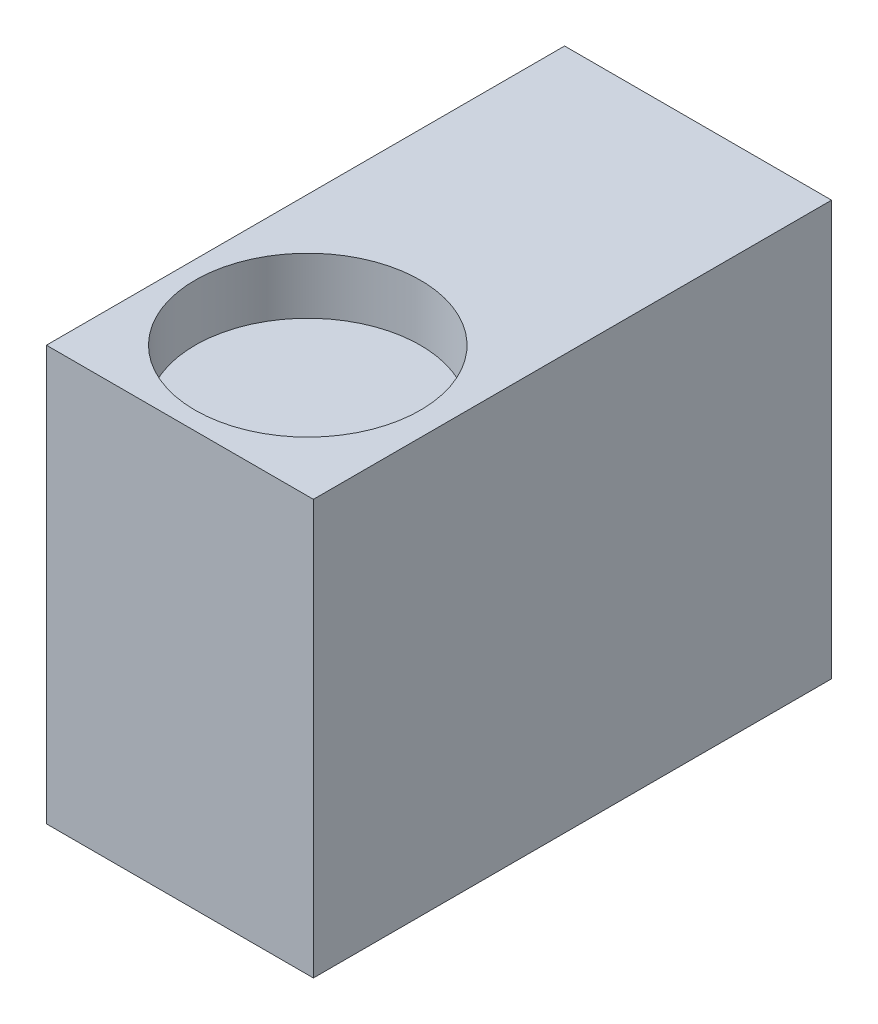
from build123d import *

# Parameters (mm, degrees)
SKETCH1_W           = 23.7
SKETCH1_H           = 36.8
BOSS_EXTRUDE2_DEPTH = 46
SKETCH2_R           = 10
CUT_EXTRUDE1_DEPTH  = 5


with BuildPart() as part:
    # Sketch1 → Boss-Extrude2 (new body)
    with BuildSketch(Plane.XY):
        with Locations((-2.757896825, -4.218611111)):
            Rectangle(SKETCH1_W, SKETCH1_H)
    extrude(amount=BOSS_EXTRUDE2_DEPTH)

    # Sketch2 → Cut-Extrude1 (cut)
    with BuildSketch(Plane(origin=(0, 14.181388889, 0), x_dir=(1, 0, 0), z_dir=(0, 1, 0))):
        with Locations((-3.007896825, -34.4)):
            Circle(SKETCH2_R)
    cut_extrude1 = extrude(amount=-CUT_EXTRUDE1_DEPTH, mode=Mode.SUBTRACT)

    # Mirror1: Cut-Extrude1 across plane
    add(cut_extrude1.mirror(Plane.ZX.offset(-4.218611111)), mode=Mode.SUBTRACT)


solid = part.part
